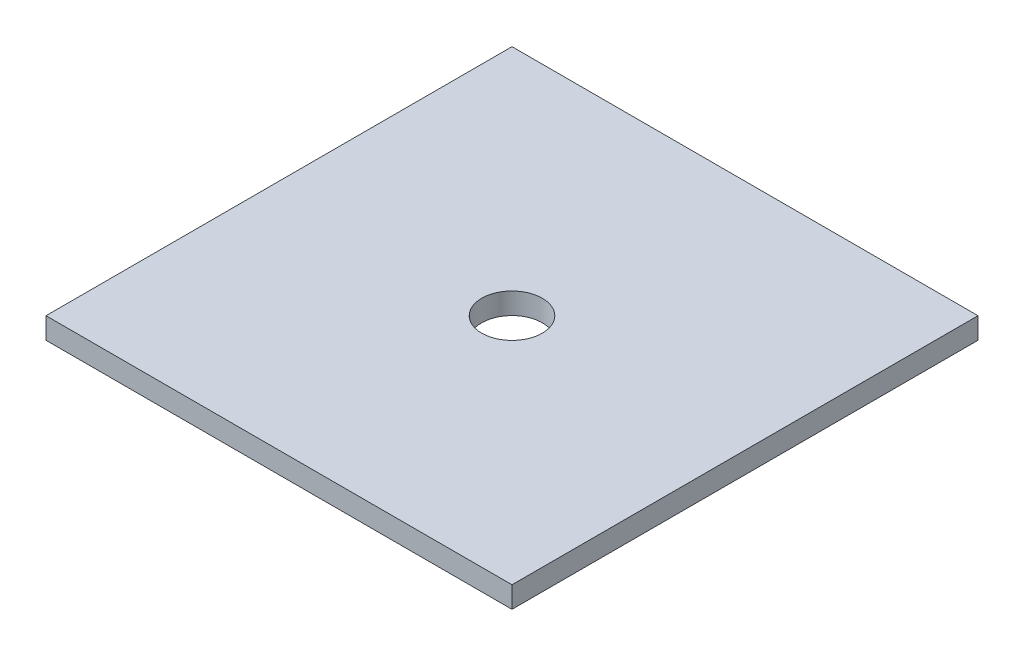
from build123d import *

# Parameters (mm, degrees)
CROQUIS1_W              = 350
CROQUIS1_H              = 350
CROQUIS1_R              = 22.75
SALIENTE_EXTRUIR1_DEPTH = 16


with BuildPart() as part:
    # Croquis1 → Saliente-Extruir1 (new body)
    with BuildSketch(Plane(origin=(0, 0, 0), x_dir=(1, 0, 0), z_dir=(0, 1, 0))):
        Rectangle(CROQUIS1_W, CROQUIS1_H)
        Circle(CROQUIS1_R, mode=Mode.SUBTRACT)
    extrude(amount=SALIENTE_EXTRUIR1_DEPTH)


solid = part.part
